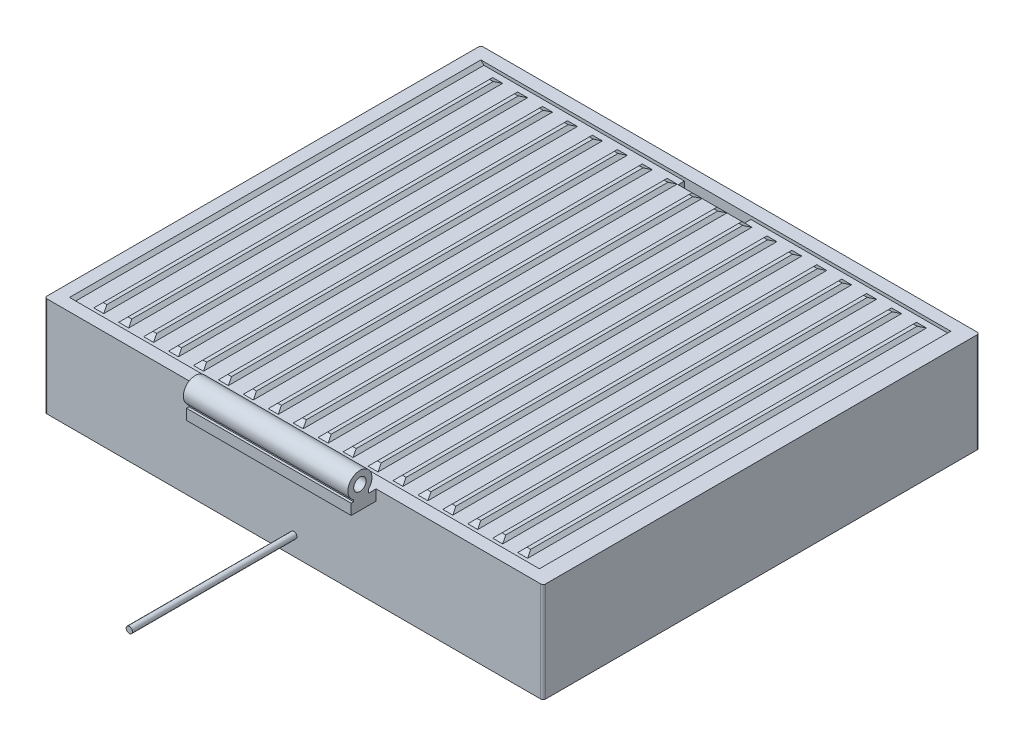
from build123d import *

# Parameters (mm, degrees)
SKETCH1_W             = 400
SKETCH1_H             = 80
BOSS_EXTRUDE1_DEPTH   = 175
CUT_EXTRUDE2_DEPTH    = 165
CUT_EXTRUDE3_DEPTH    = 187
BOSS_EXTRUDE2_DEPTH   = 2
BOSS_EXTRUDE2_2_DEPTH = 2
BOSS_EXTRUDE2_3_DEPTH = 2
BOSS_EXTRUDE2_4_DEPTH = 2
BOSS_EXTRUDE2_5_DEPTH = 2
BOSS_EXTRUDE2_6_DEPTH = 2
BOSS_EXTRUDE2_7_DEPTH = 2
BOSS_EXTRUDE2_8_DEPTH = 2
BOSS_EXTRUDE2_9_DEPTH = 2
SKETCH7_R             = 5
BOSS_EXTRUDE3_DEPTH   = 66
SKETCH8_R             = 2.5
BOSS_EXTRUDE4_DEPTH   = 132
SKETCH9_W             = 53.372944672
SKETCH9_H             = 5.061045422
CUT_EXTRUDE4_DEPTH    = 50
SKETCH10_W            = 200
SKETCH10_H            = 50
SKETCH10_W_2          = 196
SKETCH10_H_2          = 46
CUT_EXTRUDE5_DEPTH    = 330
BOSS_EXTRUDE5_DEPTH   = 25
SKETCH12_R            = 6.023243484
BOSS_EXTRUDE6_DEPTH   = 3
BOSS_EXTRUDE6_2_DEPTH = 3
SKETCH13_W            = 50
SKETCH13_H            = 5
CUT_EXTRUDE6_DEPTH    = 3
SKETCH14_W            = 10
SKETCH14_H            = 4
BOSS_EXTRUDE7_DEPTH   = 6
SKETCH15_W            = 4
SKETCH15_H            = 1
BOSS_EXTRUDE8_DEPTH   = 1
BOSS_EXTRUDE8_2_DEPTH = 1
FILLET2_R             = 2


with BuildPart() as part:
    # Sketch1 → Boss-Extrude1 (new body, symmetric)
    with BuildSketch(Plane.XY):
        Rectangle(SKETCH1_W, SKETCH1_H)
    extrude(amount=BOSS_EXTRUDE1_DEPTH, both=True)

    # Sketch2 → Cut-Extrude2 (cut, symmetric)
    with BuildSketch(Plane.XY):
        Polygon((-187.5, 37.5), (-175.5, 37.5), (-173, 40), (-190, 40), align=None)
        Polygon((-170, 40), (-153, 40), (-155.5, 37.5), (-167.5, 37.5), align=None)
        Polygon((-110, 40), (-93, 40), (-95.5, 37.5), (-107.5, 37.5), align=None)
        Polygon((-150, 40), (-133, 40), (-135.5, 37.5), (-147.5, 37.5), align=None)
        Polygon((-130, 40), (-113, 40), (-115.5, 37.5), (-127.5, 37.5), align=None)
        Polygon((-87.5, 37.5), (-75.5, 37.5), (-73, 40), (-90, 40), align=None)
        Polygon((-67.5, 37.5), (-55.5, 37.5), (-53, 40), (-70, 40), align=None)
        Polygon((-47.5, 37.5), (-35.5, 37.5), (-33, 40), (-50, 40), align=None)
        Polygon((-27.5, 37.5), (-15.5, 37.5), (-13, 40), (-30, 40), align=None)
        Polygon((-7.5, 37.5), (4.5, 37.5), (7, 40), (-10, 40), align=None)
        Polygon((12.5, 37.5), (24.5, 37.5), (27, 40), (10, 40), align=None)
        Polygon((32.5, 37.5), (44.5, 37.5), (47, 40), (30, 40), align=None)
        Polygon((52.5, 37.5), (64.5, 37.5), (67, 40), (50, 40), align=None)
        Polygon((72.5, 37.5), (84.5, 37.5), (87, 40), (70, 40), align=None)
        Polygon((92.5, 37.5), (104.5, 37.5), (107, 40), (90, 40), align=None)
        Polygon((112.5, 37.5), (124.5, 37.5), (127, 40), (110, 40), align=None)
        Polygon((132.5, 37.5), (144.5, 37.5), (147, 40), (130, 40), align=None)
        Polygon((152.5, 37.5), (164.5, 37.5), (167, 40), (150, 40), align=None)
        Polygon((172.5, 37.5), (184.5, 37.5), (187, 40), (170, 40), align=None)
    extrude(amount=CUT_EXTRUDE2_DEPTH, both=True, mode=Mode.SUBTRACT)

    # Sketch5 → Cut-Extrude3 (cut, symmetric)
    with BuildSketch(Plane(origin=(0, 0, 0), x_dir=(0, 0, -1), z_dir=(1, 0, 0))):
        Polygon((-165, 37.5), (-160, 37.5), (-155, 40), (-165, 40), align=None)
        Polygon((155, 40), (165, 40), (165, 37.5), (160, 37.5), align=None)
    extrude(amount=CUT_EXTRUDE3_DEPTH, both=True, mode=Mode.SUBTRACT)

    # Sketch7 → Boss-Extrude3 (add, symmetric)
    with BuildSketch(Plane(origin=(0, 0, 0), x_dir=(0, 0, -1), z_dir=(1, 0, 0))):
        with BuildLine():
            Line((-175, 31.5), (-195, 31.5))
            Line((-195, 31.5), (-195, 40))
            Line((-195, 40), (-193, 40))
            Line((-193, 40), (-193, 41.393550903))
            ThreePointArc((-193, 41.393550903), (-189.282641679, 59.247860474), (-181, 43))
            Line((-181, 43), (-181, 40))
            Line((-181, 40), (-175, 40))
            Line((-175, 40), (-175, 31.5))
        make_face()
        with Locations((-188, 49.666666667)):
            Circle(SKETCH7_R, mode=Mode.SUBTRACT)
    extrude(amount=BOSS_EXTRUDE3_DEPTH, both=True)

    # Sketch8 → Boss-Extrude4 (add)
    with BuildSketch(Plane.XY.offset(175)):
        with Locations((0, -25)):
            Circle(SKETCH8_R)
    extrude(amount=BOSS_EXTRUDE4_DEPTH)

    # Sketch9 → Cut-Extrude4 (cut)
    with BuildSketch(Plane(origin=(0, 37.5, 0), x_dir=(1, 0, 0), z_dir=(0, 1, 0))):
        with Locations((0, 162.469477289)):
            Rectangle(SKETCH9_W, SKETCH9_H)
    extrude(amount=-CUT_EXTRUDE4_DEPTH, mode=Mode.SUBTRACT)

    # Sketch10 → Cut-Extrude5 (cut)
    with BuildSketch(Plane(origin=(0, 0, -175), x_dir=(-1, 0, 0), z_dir=(0, 0, -1))):
        Rectangle(SKETCH10_W, SKETCH10_H)
        Rectangle(SKETCH10_W_2, SKETCH10_H_2, mode=Mode.SUBTRACT)
    extrude(amount=-CUT_EXTRUDE5_DEPTH, mode=Mode.SUBTRACT)

    # Sketch11 → Boss-Extrude5 (add, symmetric)
    with BuildSketch(Plane(origin=(0, 0, 0), x_dir=(0, 0, -1), z_dir=(1, 0, 0))):
        Polygon((175, 10), (190, 10), (190, 0), (185, 0), (185, 5), (175, 5), align=None)
    extrude(amount=BOSS_EXTRUDE5_DEPTH, both=True)

    # Sketch13 → Cut-Extrude6 (cut)
    with BuildSketch(Plane(origin=(0, 0, -175), x_dir=(-1, 0, 0), z_dir=(0, 0, -1))):
        with Locations((-163.5, 10)):
            Rectangle(SKETCH13_W, SKETCH13_H)
    extrude(amount=-CUT_EXTRUDE6_DEPTH, mode=Mode.SUBTRACT)

    # Fillet2
    fillet2_edges = [part.edges().sort_by_distance(p)[0] for p in [
        (-200, 0, 175),
        (200, 0, 175),
        (-200, 0, -175),
        (200, 0, -175),
    ]]
    fillet(fillet2_edges, radius=FILLET2_R)


with BuildPart() as body_2:
    # Sketch6 → Boss-Extrude2 (new body)
    with BuildSketch(Plane(origin=(0, 0, -175), x_dir=(-1, 0, 0), z_dir=(0, 0, -1))):
        with BuildLine():
            Line((-194.084134615, -22.0625), (-192.28897486, -22.0625))
            add(Edge.make_bspline(
                [(-192.28897486, -22.0625), (-192.149021509, -22.063478322), (-191.878490099, -22.065369429), (-191.486543607, -22.086677659), (-191.122083245, -22.119448203), (-190.784874075, -22.164530026), (-190.475607431, -22.224185623), (-190.194682105, -22.299011877), (-189.941155246, -22.385386339), (-189.712246982, -22.48702342), (-189.503275755, -22.605522164), (-189.304850905, -22.737520251), (-189.117362036, -22.887853156), (-188.938178037, -23.053620659), (-188.769611315, -23.237855425), (-188.608854632, -23.437505859), (-188.45984404, -23.655467168), (-188.318075272, -23.886513326), (-188.189864285, -24.131623486), (-188.078033871, -24.38871132), (-187.984352856, -24.656122373), (-187.90823218, -24.934141636), (-187.847555216, -25.221846169), (-187.805100767, -25.519816532), (-187.778855004, -25.827776855), (-187.77619259, -26.036496687), (-187.774839744, -26.142553085)],
                knots=[0, 0, 0, 0, 1.44355588, 2.790409838, 4.047694926, 5.217575253, 6.298404546, 7.294384826, 8.214239204, 9.058592145, 9.873746385, 10.689560431, 11.514393297, 12.350027578, 13.205127629, 14.088021785, 14.991911688, 15.926770944, 16.882954281, 17.842803888, 18.816321264, 19.80318086, 20.814351908, 21.847355356, 22.906180909, 24, 24, 24, 24], degree=3))
            add(Edge.make_bspline(
                [(-187.774839744, -26.142553085), (-187.778382227, -26.292205566), (-187.785355813, -26.586805234), (-187.844097403, -27.019126854), (-187.939102444, -27.433550245), (-188.072688161, -27.826833628), (-188.23829869, -28.195474756), (-188.436139011, -28.532972797), (-188.663308326, -28.837516233), (-188.917160098, -29.107588686), (-189.192019741, -29.33971962), (-189.477654336, -29.538522778), (-189.776846484, -29.695295657), (-190.040476581, -29.794713106), (-190.269076763, -29.856542158), (-190.469785251, -29.893083723), (-190.697769614, -29.926594542), (-190.955155608, -29.952490982), (-191.240814137, -29.975584243), (-191.55588384, -29.988132222), (-191.899344611, -29.99855773), (-192.137910591, -29.999506646), (-192.261944111, -30)],
                knots=[0, 0, 0, 0, 1.315458931, 2.589557908, 3.828601765, 5.048913369, 6.235739168, 7.376350998, 8.481830359, 9.569842114, 10.627874879, 11.640079404, 12.624025415, 13.590060155, 14.111227486, 14.704434459, 15.382649715, 16.137166398, 16.978595427, 17.902333227, 18.909396075, 20, 20, 20, 20], degree=3))
            Line((-192.261944111, -30), (-194.084134615, -30))
            Line((-194.084134615, -30), (-194.084134615, -22.0625))
        make_face()
        with BuildLine():
            Line((-192.659455128, -23.487179487), (-192.659455128, -28.575320513))
            Line((-192.659455128, -28.575320513), (-191.915314503, -28.575320513))
            add(Edge.make_bspline(
                [(-191.915314503, -28.575320513), (-191.826773197, -28.575158268), (-191.65647879, -28.574846219), (-191.410612214, -28.559983015), (-191.183247972, -28.545064456), (-190.975011946, -28.516748534), (-190.784388657, -28.485206589), (-190.613996772, -28.441311654), (-190.460323772, -28.395203743), (-190.325246744, -28.336502657), (-190.201527192, -28.270430679), (-190.086977019, -28.193019696), (-189.97640403, -28.107057719), (-189.871875477, -28.010016484), (-189.772995744, -27.903180999), (-189.680349867, -27.786000789), (-189.592701268, -27.658833373), (-189.51229972, -27.521006386), (-189.438828355, -27.373975312), (-189.373651022, -27.219164361), (-189.319609395, -27.055284292), (-189.274693303, -26.883869218), (-189.242595663, -26.703426779), (-189.216040987, -26.515293484), (-189.202351278, -26.318723967), (-189.200472451, -26.184971498), (-189.199519231, -26.11711238)],
                knots=[0, 0, 0, 0, 1.50275155, 2.890291501, 4.180787663, 5.369391935, 6.45668281, 7.458360028, 8.354766181, 9.177074746, 9.954075863, 10.732690366, 11.5210699, 12.329727389, 13.151100085, 13.990027547, 14.863562427, 15.770965086, 16.696477834, 17.652329173, 18.619756807, 19.62365428, 20.657822005, 21.729286259, 22.847956731, 24, 24, 24, 24], degree=3))
            add(Edge.make_bspline(
                [(-189.199519231, -26.11711238), (-189.201417722, -26.013124696), (-189.205119632, -25.810356771), (-189.240820056, -25.515020862), (-189.298933536, -25.23691786), (-189.381855872, -24.977079881), (-189.486382046, -24.734776642), (-189.61722092, -24.512060967), (-189.768741691, -24.305191537), (-189.888560182, -24.183835292), (-189.948429988, -24.123197115)],
                knots=[0, 0, 0, 0, 1.13821349, 2.219428113, 3.251817212, 4.244760574, 5.201143372, 6.134805572, 7.068016741, 8, 8, 8, 8], degree=3))
            add(Edge.make_bspline(
                [(-189.948429988, -24.123197115), (-190.007467285, -24.071525192), (-190.128044281, -23.965991138), (-190.339737861, -23.839534353), (-190.573013222, -23.728429673), (-190.833207005, -23.640336052), (-191.117804553, -23.570667861), (-191.428500935, -23.522619413), (-191.763632304, -23.49174399), (-191.995803508, -23.488733585), (-192.115660056, -23.487179487)],
                knots=[0, 0, 0, 0, 0.813307809, 1.661089106, 2.549956539, 3.493439533, 4.508053171, 5.589449661, 6.755572447, 8, 8, 8, 8], degree=3))
            Line((-192.115660056, -23.487179487), (-192.659455128, -23.487179487))
        make_face(mode=Mode.SUBTRACT)
    extrude(amount=BOSS_EXTRUDE2_DEPTH)


with BuildPart() as body_3:
    # Sketch6 → Boss-Extrude2 2 (new body)
    with BuildSketch(Plane(origin=(0, 0, -175), x_dir=(-1, 0, 0), z_dir=(0, 0, -1))):
        with BuildLine():
            Line((-186.350160256, -22.0625), (-184.690154247, -22.0625))
            add(Edge.make_bspline(
                [(-184.690154247, -22.0625), (-184.580428355, -22.062889464), (-184.369394557, -22.063638513), (-184.065095346, -22.07545652), (-183.785554673, -22.091902247), (-183.530358652, -22.116998862), (-183.299616461, -22.150273941), (-183.093096842, -22.189499752), (-182.910805831, -22.234205974), (-182.751206056, -22.289913453), (-182.60717515, -22.352750646), (-182.472918322, -22.424951732), (-182.345473667, -22.50571273), (-182.225693013, -22.597158681), (-182.112535439, -22.697644494), (-182.005787467, -22.807271318), (-181.906957544, -22.926968744), (-181.816657629, -23.055980435), (-181.734356525, -23.191697776), (-181.661619611, -23.334307107), (-181.602469831, -23.483907603), (-181.55020466, -23.638337215), (-181.512559751, -23.799803543), (-181.486378267, -23.966734686), (-181.467209209, -24.139718259), (-181.46610708, -24.257235618), (-181.465544872, -24.317182492)],
                knots=[0, 0, 0, 0, 1.749336639, 3.364467119, 4.854658419, 6.213483162, 7.451590619, 8.570285859, 9.5643256, 10.440900261, 11.26203566, 12.067320669, 12.869050712, 13.665104639, 14.467235401, 15.27997916, 16.102287765, 16.939272006, 17.78853747, 18.631303466, 19.488103222, 20.351255419, 21.228522269, 22.127379805, 23.044756219, 24, 24, 24, 24], degree=3))
            add(Edge.make_bspline(
                [(-181.465544872, -24.317182492), (-181.467005286, -24.379753257), (-181.469868892, -24.502443123), (-181.485293833, -24.68266453), (-181.513485778, -24.855087766), (-181.556186581, -25.019207997), (-181.605265608, -25.177067892), (-181.670528124, -25.325754835), (-181.744183324, -25.467431263), (-181.831661453, -25.600093111), (-181.927664426, -25.726687061), (-182.039313864, -25.842362831), (-182.159376598, -25.953337554), (-182.294601792, -26.052660151), (-182.439028595, -26.147046458), (-182.595526614, -26.232585587), (-182.763074489, -26.311427797), (-182.880868943, -26.355395659), (-182.941105769, -26.377879607)],
                knots=[0, 0, 0, 0, 1.099860209, 2.156625411, 3.176576793, 4.16617041, 5.135385252, 6.078461593, 7.016046972, 7.938469504, 8.868247731, 9.803980173, 10.76021508, 11.73834243, 12.748633912, 13.790971185, 14.870363756, 16, 16, 16, 16], degree=3))
            Line((-182.941105769, -26.377879607), (-181.109375, -30))
            Line((-181.109375, -30), (-182.693058894, -30))
            Line((-182.693058894, -30), (-184.442107372, -26.540064103))
            Line((-184.442107372, -26.540064103), (-184.925480769, -26.540064103))
            Line((-184.925480769, -26.540064103), (-184.925480769, -30))
            Line((-184.925480769, -30), (-186.350160256, -30))
            Line((-186.350160256, -30), (-186.350160256, -22.0625))
        make_face()
        with BuildLine():
            Line((-184.925480769, -25.115384615), (-184.370555389, -25.115384615))
            add(Edge.make_bspline(
                [(-184.370555389, -25.115384615), (-184.302711148, -25.114620508), (-184.172804005, -25.113157406), (-183.985980472, -25.106370935), (-183.816300148, -25.090018892), (-183.66303437, -25.069358697), (-183.525411918, -25.045503518), (-183.404660336, -25.011317599), (-183.298919026, -24.974686521), (-183.209441026, -24.929163593), (-183.132993079, -24.877394151), (-183.06698517, -24.818582777), (-183.012387165, -24.750516101), (-182.967450222, -24.67504388), (-182.932494166, -24.591498583), (-182.906978923, -24.500797346), (-182.892719675, -24.401906966), (-182.8910791, -24.333659138), (-182.890224359, -24.298101963)],
                knots=[0, 0, 0, 0, 1.688639943, 3.233382647, 4.650958383, 5.928841754, 7.082724185, 8.122798841, 9.049171256, 9.863274652, 10.613301712, 11.341792392, 12.054588806, 12.776240173, 13.521029143, 14.301969904, 15.115324896, 16, 16, 16, 16], degree=3))
            add(Edge.make_bspline(
                [(-182.890224359, -24.298101963), (-182.891840325, -24.256035229), (-182.895014591, -24.173402925), (-182.926513171, -24.054441382), (-182.976652105, -23.944334335), (-183.045378852, -23.843579274), (-183.131931255, -23.755250432), (-183.231256966, -23.677387855), (-183.345499673, -23.615819955), (-183.451279823, -23.575210424), (-183.547515035, -23.550913322), (-183.634364277, -23.532807337), (-183.734936223, -23.519975106), (-183.849306797, -23.50636424), (-183.977184467, -23.497538283), (-184.119266242, -23.491097093), (-184.275144064, -23.488461686), (-184.38380571, -23.487619193), (-184.440517328, -23.487179487)],
                knots=[0, 0, 0, 0, 1.020303359, 2.004196876, 2.966617323, 3.9489082, 4.950758222, 5.960522915, 7.003732012, 8.091992268, 8.70421221, 9.413913587, 10.24622431, 11.166358409, 12.212345909, 13.359657661, 14.621978493, 16, 16, 16, 16], degree=3))
            Line((-184.440517328, -23.487179487), (-184.925480769, -23.487179487))
            Line((-184.925480769, -23.487179487), (-184.925480769, -25.115384615))
        make_face(mode=Mode.SUBTRACT)
    extrude(amount=BOSS_EXTRUDE2_2_DEPTH)


with BuildPart() as body_4:
    # Sketch6 → Boss-Extrude2 3 (new body)
    with BuildSketch(Plane(origin=(0, 0, -175), x_dir=(-1, 0, 0), z_dir=(0, 0, -1))):
        with BuildLine():
            add(Edge.make_bspline(
                [(-179.379407051, -28.371794872), (-179.32189443, -28.374948151), (-179.20866201, -28.381156412), (-179.045056604, -28.427488018), (-178.897401782, -28.510729349), (-178.765378642, -28.619303238), (-178.6537432, -28.749932123), (-178.573055627, -28.898898395), (-178.522809452, -29.061873407), (-178.517262239, -29.175462069), (-178.514423077, -29.233598758)],
                knots=[0, 0, 0, 0, 1.016957001, 2.002212695, 2.9757545, 3.99499976, 5.013036768, 5.994806404, 6.97370641, 8, 8, 8, 8], degree=3))
            add(Edge.make_bspline(
                [(-178.514423077, -29.233598758), (-178.51724364, -29.291744784), (-178.522754513, -29.405351689), (-178.573403326, -29.56864427), (-178.653622627, -29.718834908), (-178.765387599, -29.850863567), (-178.896855028, -29.961483633), (-179.045396088, -30.043957357), (-179.208350345, -30.092917238), (-179.321839573, -30.098785925), (-179.379407051, -30.101762821)],
                knots=[0, 0, 0, 0, 1.023218912, 1.999186227, 2.986238111, 4.008388923, 5.030539734, 6.0011649, 6.986089706, 8, 8, 8, 8], degree=3))
            add(Edge.make_bspline(
                [(-179.379407051, -30.101762821), (-179.43698817, -30.098810132), (-179.550504289, -30.092989167), (-179.713711847, -30.043544674), (-179.863349552, -29.962034259), (-179.994850013, -29.850729385), (-180.107114301, -29.719302433), (-180.185052894, -29.568170392), (-180.236173486, -29.405413252), (-180.241609022, -29.291765626), (-180.244391026, -29.233598758)],
                knots=[0, 0, 0, 0, 1.013427518, 1.99788335, 2.976245624, 3.997909735, 5.019573847, 6.001765691, 6.977268297, 8, 8, 8, 8], degree=3))
            add(Edge.make_bspline(
                [(-180.244391026, -29.233598758), (-180.241590668, -29.175440865), (-180.236119272, -29.061810772), (-180.185399602, -28.899377731), (-180.106989391, -28.749462058), (-179.994859376, -28.619437699), (-179.862799982, -28.510183021), (-179.714053236, -28.427895047), (-179.550192781, -28.381083951), (-179.436933378, -28.374923743), (-179.379407051, -28.371794872)],
                knots=[0, 0, 0, 0, 1.025808215, 2.00424526, 2.981110158, 3.998665696, 5.017428914, 5.998734231, 6.983523959, 8, 8, 8, 8], degree=3))
        make_face()
    extrude(amount=BOSS_EXTRUDE2_3_DEPTH)


with BuildPart() as body_5:
    # Sketch6 → Boss-Extrude2 4 (new body)
    with BuildSketch(Plane(origin=(0, 0, -175), x_dir=(-1, 0, 0), z_dir=(0, 0, -1))):
        Polygon((-173.833333333, -22.0625), (-169.966346154, -22.0625), (-169.966346154, -23.487179487), (-172.408653846, -23.487179487), (-172.408653846, -25.013621795), (-169.966346154, -25.013621795), (-169.966346154, -26.438301282), (-172.408653846, -26.438301282), (-172.408653846, -30), (-173.833333333, -30), align=None)
    extrude(amount=BOSS_EXTRUDE2_4_DEPTH)


with BuildPart() as body_6:
    # Sketch6 → Boss-Extrude2 5 (new body)
    with BuildSketch(Plane(origin=(0, 0, -175), x_dir=(-1, 0, 0), z_dir=(0, 0, -1))):
        with BuildLine():
            Line((-168.541666667, -22.0625), (-166.881660657, -22.0625))
            add(Edge.make_bspline(
                [(-166.881660657, -22.0625), (-166.771934765, -22.062889464), (-166.560900967, -22.063638513), (-166.256601756, -22.07545652), (-165.977061083, -22.091902247), (-165.721865062, -22.116998862), (-165.491122871, -22.150273941), (-165.284603252, -22.189499752), (-165.102312241, -22.234205974), (-164.942712466, -22.289913453), (-164.79868156, -22.352750646), (-164.664424733, -22.424951732), (-164.536980077, -22.50571273), (-164.417199423, -22.597158681), (-164.304041849, -22.697644494), (-164.197293877, -22.807271318), (-164.098463954, -22.926968744), (-164.008164039, -23.055980435), (-163.925862935, -23.191697776), (-163.853126021, -23.334307107), (-163.793976242, -23.483907603), (-163.741711071, -23.638337215), (-163.704066161, -23.799803543), (-163.677884677, -23.966734686), (-163.658715619, -24.139718259), (-163.65761349, -24.257235618), (-163.657051282, -24.317182492)],
                knots=[0, 0, 0, 0, 1.749336639, 3.364467119, 4.854658419, 6.213483162, 7.451590619, 8.570285859, 9.5643256, 10.440900261, 11.26203566, 12.067320669, 12.869050712, 13.665104639, 14.467235401, 15.27997916, 16.102287765, 16.939272006, 17.78853747, 18.631303466, 19.488103222, 20.351255419, 21.228522269, 22.127379805, 23.044756219, 24, 24, 24, 24], degree=3))
            add(Edge.make_bspline(
                [(-163.657051282, -24.317182492), (-163.658511696, -24.379753257), (-163.661375302, -24.502443123), (-163.676800243, -24.68266453), (-163.704992188, -24.855087766), (-163.747692992, -25.019207997), (-163.796772018, -25.177067892), (-163.862034535, -25.325754835), (-163.935689734, -25.467431263), (-164.023167863, -25.600093111), (-164.119170836, -25.726687061), (-164.230820274, -25.842362831), (-164.350883008, -25.953337554), (-164.486108203, -26.052660151), (-164.630535005, -26.147046458), (-164.787033024, -26.232585587), (-164.954580899, -26.311427797), (-165.072375353, -26.355395659), (-165.132612179, -26.377879607)],
                knots=[0, 0, 0, 0, 1.099860209, 2.156625411, 3.176576793, 4.16617041, 5.135385252, 6.078461593, 7.016046972, 7.938469504, 8.868247731, 9.803980173, 10.76021508, 11.73834243, 12.748633912, 13.790971185, 14.870363756, 16, 16, 16, 16], degree=3))
            Line((-165.132612179, -26.377879607), (-163.30088141, -30))
            Line((-163.30088141, -30), (-164.884565304, -30))
            Line((-164.884565304, -30), (-166.633613782, -26.540064103))
            Line((-166.633613782, -26.540064103), (-167.116987179, -26.540064103))
            Line((-167.116987179, -26.540064103), (-167.116987179, -30))
            Line((-167.116987179, -30), (-168.541666667, -30))
            Line((-168.541666667, -30), (-168.541666667, -22.0625))
        make_face()
        with BuildLine():
            Line((-167.116987179, -25.115384615), (-166.562061799, -25.115384615))
            add(Edge.make_bspline(
                [(-166.562061799, -25.115384615), (-166.494217558, -25.114620508), (-166.364310415, -25.113157406), (-166.177486882, -25.106370935), (-166.007806558, -25.090018892), (-165.85454078, -25.069358697), (-165.716918328, -25.045503518), (-165.596166746, -25.011317599), (-165.490425436, -24.974686521), (-165.400947436, -24.929163593), (-165.324499489, -24.877394151), (-165.25849158, -24.818582777), (-165.203893575, -24.750516101), (-165.158956632, -24.67504388), (-165.124000576, -24.591498583), (-165.098485333, -24.500797346), (-165.084226085, -24.401906966), (-165.08258551, -24.333659138), (-165.081730769, -24.298101963)],
                knots=[0, 0, 0, 0, 1.688639943, 3.233382647, 4.650958383, 5.928841754, 7.082724185, 8.122798841, 9.049171256, 9.863274652, 10.613301712, 11.341792392, 12.054588806, 12.776240173, 13.521029143, 14.301969904, 15.115324896, 16, 16, 16, 16], degree=3))
            add(Edge.make_bspline(
                [(-165.081730769, -24.298101963), (-165.083346735, -24.256035229), (-165.086521001, -24.173402925), (-165.118019581, -24.054441382), (-165.168158516, -23.944334335), (-165.236885263, -23.843579274), (-165.323437665, -23.755250432), (-165.422763376, -23.677387855), (-165.537006083, -23.615819955), (-165.642786234, -23.575210424), (-165.739021445, -23.550913322), (-165.825870687, -23.532807337), (-165.926442633, -23.519975106), (-166.040813208, -23.50636424), (-166.168690878, -23.497538283), (-166.310772652, -23.491097093), (-166.466650474, -23.488461686), (-166.57531212, -23.487619193), (-166.632023738, -23.487179487)],
                knots=[0, 0, 0, 0, 1.020303359, 2.004196876, 2.966617323, 3.9489082, 4.950758222, 5.960522915, 7.003732012, 8.091992268, 8.70421221, 9.413913587, 10.24622431, 11.166358409, 12.212345909, 13.359657661, 14.621978493, 16, 16, 16, 16], degree=3))
            Line((-166.632023738, -23.487179487), (-167.116987179, -23.487179487))
            Line((-167.116987179, -23.487179487), (-167.116987179, -25.115384615))
        make_face(mode=Mode.SUBTRACT)
    extrude(amount=BOSS_EXTRUDE2_5_DEPTH)


with BuildPart() as body_7:
    # Sketch6 → Boss-Extrude2 6 (new body)
    with BuildSketch(Plane(origin=(0, 0, -175), x_dir=(-1, 0, 0), z_dir=(0, 0, -1))):
        Polygon((-162.130608974, -22.0625), (-157.856570513, -22.0625), (-157.856570513, -23.487179487), (-160.705929487, -23.487179487), (-160.705929487, -25.013621795), (-157.856570513, -25.013621795), (-157.856570513, -26.438301282), (-160.705929487, -26.438301282), (-160.705929487, -28.575320513), (-157.856570513, -28.575320513), (-157.856570513, -30), (-162.130608974, -30), align=None)
    extrude(amount=BOSS_EXTRUDE2_6_DEPTH)


with BuildPart() as body_8:
    # Sketch6 → Boss-Extrude2 7 (new body)
    with BuildSketch(Plane(origin=(0, 0, -175), x_dir=(-1, 0, 0), z_dir=(0, 0, -1))):
        Polygon((-156.431891026, -22.0625), (-152.157852564, -22.0625), (-152.157852564, -23.487179487), (-155.007211538, -23.487179487), (-155.007211538, -25.013621795), (-152.157852564, -25.013621795), (-152.157852564, -26.438301282), (-155.007211538, -26.438301282), (-155.007211538, -28.575320513), (-152.157852564, -28.575320513), (-152.157852564, -30), (-156.431891026, -30), align=None)
    extrude(amount=BOSS_EXTRUDE2_7_DEPTH)


with BuildPart() as body_9:
    # Sketch6 → Boss-Extrude2 8 (new body)
    with BuildSketch(Plane(origin=(0, 0, -175), x_dir=(-1, 0, 0), z_dir=(0, 0, -1))):
        Polygon((-151.140224359, -22.0625), (-146.357371795, -22.0625), (-149.200370593, -28.575320513), (-146.560897436, -28.575320513), (-146.560897436, -30), (-151.34375, -30), (-148.499161158, -23.487179487), (-151.140224359, -23.487179487), align=None)
    extrude(amount=BOSS_EXTRUDE2_8_DEPTH)


with BuildPart() as body_10:
    # Sketch6 → Boss-Extrude2 9 (new body)
    with BuildSketch(Plane(origin=(0, 0, -175), x_dir=(-1, 0, 0), z_dir=(0, 0, -1))):
        Polygon((-145.899439103, -22.0625), (-144.314165164, -22.0625), (-142.897435897, -24.846667167), (-141.480706631, -22.0625), (-139.895432692, -22.0625), (-142.185096154, -26.56232472), (-142.185096154, -30), (-143.609775641, -30), (-143.609775641, -26.56232472), align=None)
    extrude(amount=BOSS_EXTRUDE2_9_DEPTH)


with BuildPart() as body_11:
    # Sketch12 → Boss-Extrude6 (new body)
    with BuildSketch(Plane(origin=(0, 0, -175), x_dir=(-1, 0, 0), z_dir=(0, 0, -1))):
        with Locations((-182.5, 27.5)):
            Circle(SKETCH12_R)
    extrude(amount=BOSS_EXTRUDE6_DEPTH)


with BuildPart() as body_12:
    # Sketch12 → Boss-Extrude6 2 (new body)
    with BuildSketch(Plane(origin=(0, 0, -175), x_dir=(-1, 0, 0), z_dir=(0, 0, -1))):
        with Locations((-162.5, 27.5)):
            Circle(SKETCH12_R)
    extrude(amount=BOSS_EXTRUDE6_2_DEPTH)


with BuildPart() as body_13:
    # Sketch14 → Boss-Extrude7 (new body)
    with BuildSketch(Plane(origin=(0, 0, -172), x_dir=(-1, 0, 0), z_dir=(0, 0, -1))):
        with Locations((-182.5, 10)):
            Rectangle(SKETCH14_W, SKETCH14_H)
    extrude(amount=BOSS_EXTRUDE7_DEPTH)


with BuildPart() as body_14:
    # Sketch15 → Boss-Extrude8 (new body)
    with BuildSketch(Plane(origin=(0, 0, -175), x_dir=(-1, 0, 0), z_dir=(0, 0, -1))):
        with Locations((-186.5, 4)):
            Rectangle(SKETCH15_W, SKETCH15_H)
    extrude(amount=BOSS_EXTRUDE8_DEPTH)


with BuildPart() as body_15:
    # Sketch15 → Boss-Extrude8 2 (new body)
    with BuildSketch(Plane(origin=(0, 0, -175), x_dir=(-1, 0, 0), z_dir=(0, 0, -1))):
        Polygon((-138.5, 4.5), (-138.5, 3.5), (-139.5, 3.5), (-139.5, 2.5), (-140.5, 2.5), (-140.5, 3.5), (-141.5, 3.5), (-141.5, 4.5), (-140.5, 4.5), (-140.5, 5.5), (-139.5, 5.5), (-139.5, 4.5), align=None)
    extrude(amount=BOSS_EXTRUDE8_2_DEPTH)


solid = Compound([part.part, body_2.part, body_3.part, body_4.part, body_5.part, body_6.part, body_7.part, body_8.part, body_9.part, body_10.part, body_11.part, body_12.part, body_13.part, body_14.part, body_15.part])
